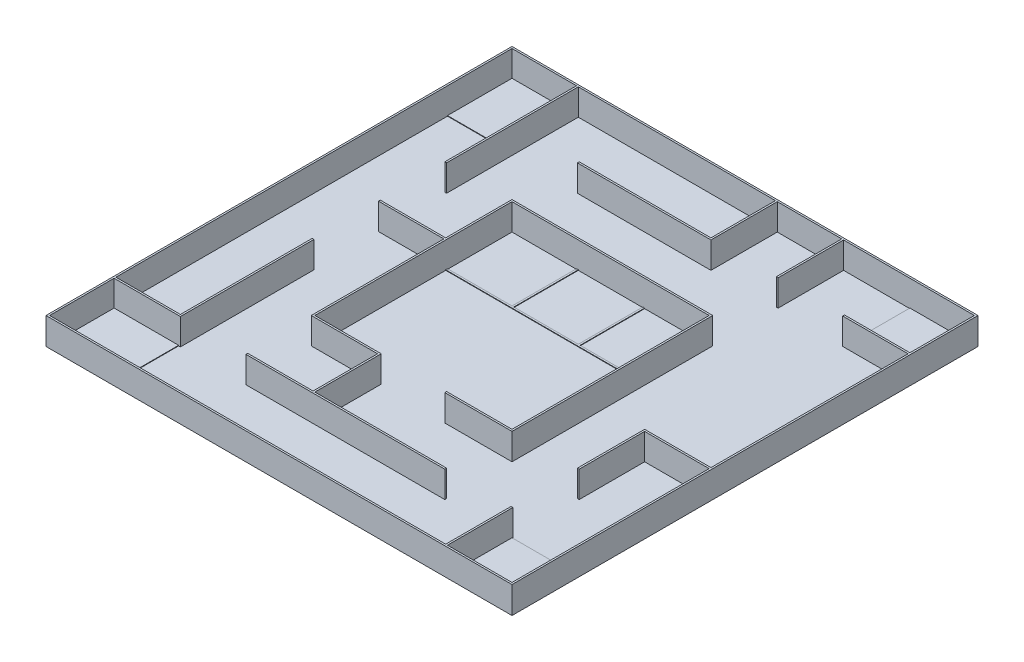
from build123d import *

# Parameters (mm, degrees)
SKETCH1_W               = 2600
SKETCH1_H               = 2600
BOSS_EXTRUDE1_DEPTH     = 150
BOSS_EXTRUDE1_2_DEPTH   = 150
SKETCH2_W               = 2600
SKETCH2_H               = 2600
BOSS_EXTRUDE2_DEPTH     = 3
SKETCH3_W               = 360
SKETCH3_H               = 360
BOSS_EXTRUDE3_DEPTH     = 3
MIRROR2_COPY_1_SKETCH_W = 360
MIRROR2_COPY_1_SKETCH_H = 360
MIRROR2_COPY_1_DEPTH    = 3
SKETCH5_W               = 10
SKETCH5_H               = 365
SKETCH5_W_2             = 1100
SKETCH5_H_2             = 10
BOSS_EXTRUDE4_DEPTH     = 3


with BuildPart() as part:
    # Sketch1 → Boss-Extrude1 (new body)
    with BuildSketch(Plane(origin=(0, 0, 0), x_dir=(1, 0, 0), z_dir=(0, 1, 0))):
        Rectangle(SKETCH1_W, SKETCH1_H)
        Polygon((920, -1290), (-1290, -1290), (-1290, -930), (-920, -930), (-920, -185), (-925, -185), (-930, -185), (-930, -920), (-1290, -920), (-1290, 1290), (-930, 1290), (-930, 555), (-920, 555), (-920, 1290), (180, 1290), (180, 930), (-555, 930), (-555, 920), (190, 920), (190, 1290), (550, 1290), (550, 925), (560, 925), (560, 1290), (1290, 1290), (1290, 930), (925, 930), (925, 920), (1290, 920), (1290, -180), (920, -180), (920, -555), (930, -555), (930, -190), (1290, -190), (1290, -1290), (930, -1290), (930, -925), (920, -925), align=None, mode=Mode.SUBTRACT)
    extrude(amount=BOSS_EXTRUDE1_DEPTH)



with BuildPart() as body_2:
    # Sketch1 → Boss-Extrude1 2 (new body)
    with BuildSketch(Plane(origin=(0, 0, 0), x_dir=(1, 0, 0), z_dir=(0, 1, 0))):
        Polygon((185, -550), (185, -560), (560, -560), (560, 560), (-560, 560), (-560, 190), (-925, 190), (-925, 180), (-560, 180), (-560, -560), (-190, -560), (-190, -920), (-555, -920), (-555, -930), (555, -930), (555, -920), (-180, -920), (-180, -550), (-550, -550), (-550, 550), (550, 550), (550, -550), align=None)
    extrude(amount=BOSS_EXTRUDE1_2_DEPTH)


with BuildPart() as part_1:
    add(part.part)

    add(body_2.part)  # Boss-Extrude2 merges body 2
    # Sketch2 → Boss-Extrude2 (add)
    with BuildSketch(Plane(origin=(0, 0, 0), x_dir=(1, 0, 0), z_dir=(0, 1, 0))):
        Rectangle(SKETCH2_W, SKETCH2_H)
    extrude(amount=BOSS_EXTRUDE2_DEPTH)

    # Sketch3 → Boss-Extrude3 (add)
    with BuildSketch(Plane(origin=(0, 3, 0), x_dir=(1, 0, 0), z_dir=(0, 1, 0))):
        with Locations((-1110, 1110)):
            Rectangle(SKETCH3_W, SKETCH3_H)
    boss_extrude3 = extrude(amount=BOSS_EXTRUDE3_DEPTH)

    # Mirror1: Boss-Extrude3 across plane
    add(boss_extrude3.mirror(Plane.XY))

    # Mirror2: Boss-Extrude3 across plane
    add(boss_extrude3.mirror(Plane(origin=(0, 0, 0), x_dir=(0, 0, 1), z_dir=(1, 0, 0))))

    # Mirror2 copy 1 sketch → Mirror2 copy 1 (add)
    with BuildSketch(Plane(origin=(0, 3, 0), x_dir=(-1, 0, 0), z_dir=(0, 1, 0))):
        with Locations((-1110, 1110)):
            Rectangle(MIRROR2_COPY_1_SKETCH_W, MIRROR2_COPY_1_SKETCH_H)
    extrude(amount=MIRROR2_COPY_1_DEPTH)

    # Sketch5 → Boss-Extrude4 (add)
    with BuildSketch(Plane(origin=(0, 3, 0), x_dir=(1, 0, 0), z_dir=(0, 1, 0))):
        with Locations((-185, 367.5)):
            Rectangle(SKETCH5_W, SKETCH5_H)
        with Locations((0, 185)):
            Rectangle(SKETCH5_W_2, SKETCH5_H_2)
        with Locations((185, 367.5)):
            Rectangle(SKETCH5_W, SKETCH5_H)
    extrude(amount=BOSS_EXTRUDE4_DEPTH)


solid = part_1.part
